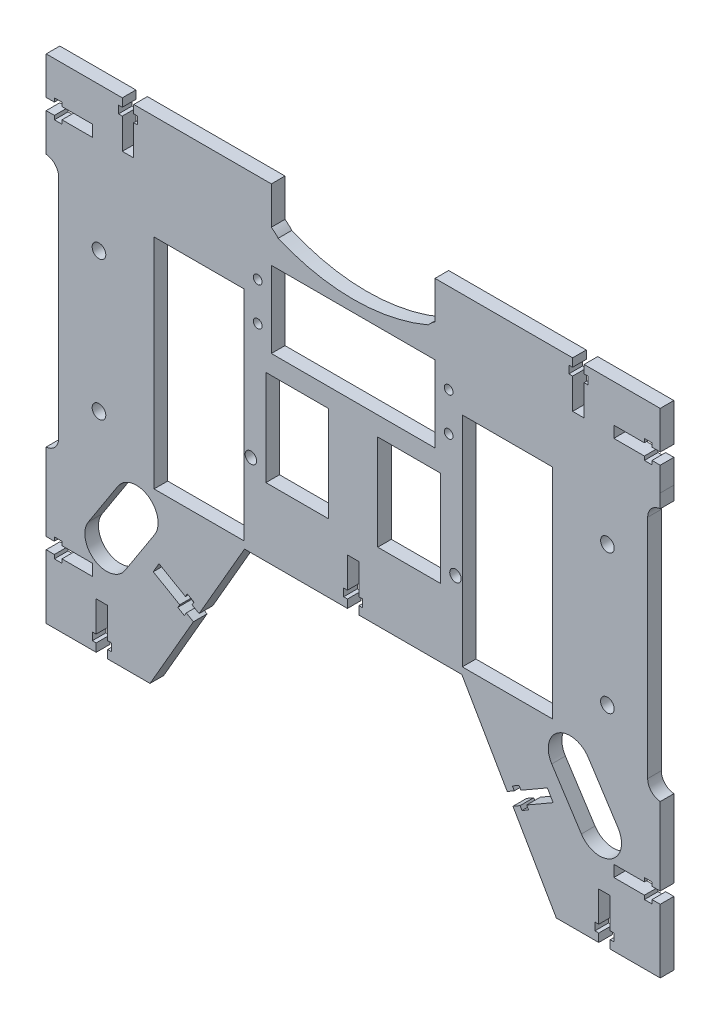
from build123d import *

# Parameters (mm, degrees)
SKETCH1_R           = 2.5
SKETCH1_W           = 33
SKETCH1_H           = 80
SKETCH1_W_2         = 31
SKETCH1_H_2         = 35
BOSS_EXTRUDE1_DEPTH = 5
CUT_EXTRUDE1_DEPTH  = 10
SKETCH3_R           = 1.6
CUT_EXTRUDE2_DEPTH  = 10
CUT_EXTRUDE3_DEPTH  = 5
CUT_EXTRUDE4_DEPTH  = 5
SKETCH6_W           = 3.16837468
SKETCH6_H           = 2.878316338
SKETCH6_W_2         = 2.517728351
SKETCH6_H_2         = 2.409312127
BOSS_EXTRUDE3_DEPTH = 5
CUT_EXTRUDE5_DEPTH  = 5
SKETCH8_W           = 4.185513975
SKETCH8_H           = 1.327509763
CUT_EXTRUDE6_DEPTH  = 5
CUT_EXTRUDE7_DEPTH  = 10
BOSS_EXTRUDE4_DEPTH = 5
SKETCH13_W          = 4.000000001
SKETCH13_H          = 35
SKETCH13_W_2        = 3.999999999
SKETCH13_W_3        = 4
BOSS_EXTRUDE5_DEPTH = 5
SKETCH15_R          = 2.1
CUT_EXTRUDE8_DEPTH  = 5
BOSS_EXTRUDE6_DEPTH = 5
CUT_EXTRUDE9_DEPTH  = 5
CUT_EXTRUDE11_DEPTH = 5


with BuildPart() as part:
    # Sketch1 → Boss-Extrude1 (new body)
    with BuildSketch(Plane.XY):
        with BuildLine():
            Line((71.862411876, -120.884610434), (117.840978496, -120.884610434))
            Line((117.840978496, -120.884610434), (117.840978496, -59.877430624))
            Line((117.840978496, -59.877430624), (113.240978496, -59.877430624))
            ThreePointArc((113.240978496, -59.877430624), (109.705444591, -58.41296453), (108.240978496, -54.877430624))
            Line((108.240978496, -54.877430624), (108.240978496, 28.108209756))
            ThreePointArc((108.240978496, 28.108209756), (109.705444591, 31.643743662), (113.240978496, 33.108209756))
            Line((113.240978496, 33.108209756), (117.839638844, 33.108209756))
            Line((117.839638844, 33.108209756), (117.839282858, 49.903611938))
            Line((117.839282858, 49.903611938), (117.822271173, 69.968834053))
            Line((117.822271173, 69.968834053), (36.921897219, 69.968834053))
            ThreePointArc((36.921897219, 69.968834053), (0.270978496, 60.403611938), (-36.379940226, 69.968834053))
            Line((-36.379940226, 69.968834053), (-117.28031418, 69.968834053))
            Line((-117.28031418, 69.968834053), (-117.297325865, 49.903611938))
            Line((-117.297325865, 49.903611938), (-117.297681851, 33.108209756))
            Line((-117.297681851, 33.108209756), (-112.699021504, 33.108209756))
            ThreePointArc((-112.699021504, 33.108209756), (-109.163487598, 31.643743662), (-107.699021504, 28.108209756))
            Line((-107.699021504, 28.108209756), (-107.699021504, -54.877430624))
            ThreePointArc((-107.699021504, -54.877430624), (-109.163487598, -58.41296453), (-112.699021504, -59.877430624))
            Line((-112.699021504, -59.877430624), (-117.299021504, -59.877430624))
            Line((-117.299021504, -59.877430624), (-117.299021504, -120.884610434))
            Line((-117.299021504, -120.884610434), (-71.320454883, -120.884610434))
            Line((-71.320454883, -120.884610434), (-36.679438732, -60.884610434))
            Line((-36.679438732, -60.884610434), (37.221395725, -60.884610434))
            Line((37.221395725, -60.884610434), (71.862411876, -120.884610434))
        make_face()
        with Locations((-92.929021504, 12.115389566)):
            Circle(SKETCH1_R, mode=Mode.SUBTRACT)
        with Locations((-92.929021504, -38.884610434)):
            Circle(SKETCH1_R, mode=Mode.SUBTRACT)
        with Locations((93.470978496, 12.115389566)):
            Circle(SKETCH1_R, mode=Mode.SUBTRACT)
        with Locations((93.470978496, -38.884610434)):
            Circle(SKETCH1_R, mode=Mode.SUBTRACT)
        with Locations((-56.229021504, -13.384610434)):
            Rectangle(SKETCH1_W, SKETCH1_H, mode=Mode.SUBTRACT)
        with Locations((-20.229021504, -13.384610434)):
            Rectangle(SKETCH1_W_2, SKETCH1_H_2, mode=Mode.SUBTRACT)
        with Locations((20.770978496, -13.384610434)):
            Rectangle(SKETCH1_W_2, SKETCH1_H_2, mode=Mode.SUBTRACT)
        with Locations((56.770978496, -13.384610434)):
            Rectangle(SKETCH1_W, SKETCH1_H, mode=Mode.SUBTRACT)
    extrude(amount=BOSS_EXTRUDE1_DEPTH)

    # Sketch2 → Cut-Extrude1 (cut)
    with BuildSketch(Plane.XY.offset(5)):
        with BuildLine():
            Line((-29.729021504, 60.403611938), (-29.729021504, 66.664976514))
            ThreePointArc((-29.729021504, 66.664976514), (0.270978496, 60.403611938), (30.270978496, 66.664976514))
            Line((30.270978496, 66.664976514), (30.270978496, 60.403611938))
            Line((30.270978496, 60.403611938), (30.270978496, 32.403611938))
            Line((30.270978496, 32.403611938), (-29.729021504, 32.403611938))
            Line((-29.729021504, 32.403611938), (-29.729021504, 60.403611938))
        make_face()
    extrude(amount=-CUT_EXTRUDE1_DEPTH, mode=Mode.SUBTRACT)

    # Sketch3 → Cut-Extrude2 (cut)
    with BuildSketch(Plane.XY.offset(5)):
        with Locations((35.270978497, 32.115389566)):
            Circle(SKETCH3_R)
        with Locations((35.270978497, 18.115389566)):
            Circle(SKETCH3_R)
        with Locations((-34.729021503, 32.115389566)):
            Circle(SKETCH3_R)
        with Locations((-34.729021503, 18.115389566)):
            Circle(SKETCH3_R)
    extrude(amount=-CUT_EXTRUDE2_DEPTH, mode=Mode.SUBTRACT)

    # Sketch4 → Cut-Extrude3 (cut)
    with BuildSketch(Plane.XY.offset(5)):
        with BuildLine():
            ThreePointArc((112.840978496, -59.861404942), (113.040818047, -59.873422597), (113.240978496, -59.877430624))
            Line((113.240978496, -59.877430624), (117.840978496, -59.877430624))
            Line((117.840978496, -59.877430624), (117.840978496, -120.884610434))
            Line((117.840978496, -120.884610434), (71.862411876, -120.884610434))
            Line((71.862411876, -120.884610434), (37.221395725, -60.884610434))
            Line((37.221395725, -60.884610434), (-36.679438732, -60.884610434))
            Line((-36.679438732, -60.884610434), (-71.320454883, -120.884610434))
            Line((-71.320454883, -120.884610434), (-117.299021504, -120.884610434))
            Line((-117.299021504, -120.884610434), (-117.299021504, -59.877430624))
            Line((-117.299021504, -59.877430624), (-112.699021504, -59.877430624))
            ThreePointArc((-112.699021504, -59.877430624), (-112.498861054, -59.873422597), (-112.299021504, -59.861404942))
            Line((-112.299021504, -59.861404942), (-112.299021504, -64.869427421))
            Line((-112.299021504, -64.869427421), (-112.299021504, -115.884610434))
            Line((-112.299021504, -115.884610434), (-74.207206229, -115.884610434))
            Line((-74.207206229, -115.884610434), (-39.566190078, -55.884610434))
            Line((-39.566190078, -55.884610434), (40.108147071, -55.884610434))
            Line((40.108147071, -55.884610434), (74.749163222, -115.884610434))
            Line((74.749163222, -115.884610434), (112.840978496, -115.884610434))
            Line((112.840978496, -115.884610434), (112.840978496, -64.869427421))
            Line((112.840978496, -64.869427421), (112.840978496, -59.861404942))
        make_face()
        with BuildLine():
            ThreePointArc((-112.297576044, 33.092067854), (-112.498136575, 33.104172651), (-112.699021504, 33.108209756))
            Line((-112.699021504, 33.108209756), (-117.297681851, 33.108209756))
            Line((-117.297681851, 33.108209756), (-117.297325865, 49.903611938))
            Line((-117.297325865, 49.903611938), (-117.28031418, 69.968834053))
            Line((-117.28031418, 69.968834053), (-36.379940226, 69.968834053))
            Line((-36.379940226, 69.968834053), (-36.379940226, 64.293063095))
            ThreePointArc((-36.379940226, 64.293063095), (-37.022706456, 64.628043677), (-37.662411338, 64.968834053))
            Line((-37.662411338, 64.968834053), (-112.28455148, 64.968834053))
            Line((-112.28455148, 64.968834053), (-112.29732591, 49.901439401))
            Line((-112.29732591, 49.901439401), (-112.297576044, 38.100148584))
            Line((-112.297576044, 38.100148584), (-112.297576044, 33.092067854))
        make_face()
        with BuildLine():
            ThreePointArc((113.240978496, 33.108209756), (113.040093568, 33.104172651), (112.839533037, 33.092067854))
            Line((112.839533037, 33.092067854), (112.839533037, 38.100148584))
            Line((112.839533037, 38.100148584), (112.839282903, 49.901439402))
            Line((112.839282903, 49.901439402), (112.826508473, 64.968834053))
            Line((112.826508473, 64.968834053), (38.204368331, 64.968834053))
            ThreePointArc((38.204368331, 64.968834053), (37.564663449, 64.628043677), (36.921897219, 64.293063095))
            Line((36.921897219, 64.293063095), (36.921897219, 69.968834053))
            Line((36.921897219, 69.968834053), (117.822271173, 69.968834053))
            Line((117.822271173, 69.968834053), (117.839282858, 49.903611938))
            Line((117.839282858, 49.903611938), (117.839638844, 33.108209756))
            Line((117.839638844, 33.108209756), (113.240978496, 33.108209756))
        make_face()
    extrude(amount=-CUT_EXTRUDE3_DEPTH, mode=Mode.SUBTRACT)

    # Sketch5 → Cut-Extrude4 (cut)
    with BuildSketch(Plane.XY.offset(5)):
        with BuildLine():
            Line((-36.379940226, 64.968834053), (-29.729021504, 64.968834053))
            Line((-29.729021504, 64.968834053), (-29.729021504, 66.664976514))
            ThreePointArc((-29.729021504, 66.664976514), (-33.095398446, 68.234535052), (-36.379940226, 69.968834053))
            Line((-36.379940226, 69.968834053), (-36.379940226, 64.968834053))
        make_face()
        with BuildLine():
            Line((36.921897219, 69.968834053), (36.921897219, 64.968834053))
            Line((36.921897219, 64.968834053), (30.270978497, 64.968834053))
            Line((30.270978497, 64.968834053), (30.270978497, 66.664976514))
            ThreePointArc((30.270978497, 66.664976514), (33.637355439, 68.234535052), (36.921897219, 69.968834053))
        make_face()
    extrude(amount=-CUT_EXTRUDE4_DEPTH, mode=Mode.SUBTRACT)

    # Sketch6 → Boss-Extrude3 (add)
    with BuildSketch(Plane.XY.offset(5)):
        with Locations((-36.078223998, 63.529675884)):
            Rectangle(SKETCH6_W, SKETCH6_H)
        with Locations((36.945504156, 63.76417799)):
            Rectangle(SKETCH6_W_2, SKETCH6_H_2)
    extrude(amount=-BOSS_EXTRUDE3_DEPTH)

    # Sketch7 → Cut-Extrude5 (cut)
    with BuildSketch(Plane.XY.offset(5)):
        Polygon((-1.828604275, -52.884610434), (-1.828604275, -55.884610434), (2.371395725, -55.884610434), (2.371395725, -52.884610434), (3.771395725, -52.884610434), (3.771395725, -50.084610434), (2.371395725, -50.084610434), (2.371395725, -38.884610434), (-1.828604275, -38.884610434), (-1.828604275, -50.084610434), (-3.228604275, -50.084610434), (-3.228604275, -52.884610434), align=None)
        Polygon((-58.308565752, -88.347357356), (-56.208565752, -84.71005066), (-58.806641963, -83.21005066), (-58.106641963, -81.997615095), (-60.531513094, -80.597615095), (-61.231513094, -81.81005066), (-70.930997615, -76.210050661), (-73.030997615, -79.847357357), (-63.331513094, -85.447357356), (-64.031513094, -86.659792921), (-61.606641963, -88.059792921), (-60.906641963, -86.847357356), align=None)
        Polygon((-93.954021504, -115.884610434), (-89.754021504, -115.884610434), (-89.754021504, -112.884610437), (-88.354021504, -112.884610437), (-88.354021504, -110.084610437), (-89.754021504, -110.084610437), (-89.754021504, -98.884610434), (-93.954021504, -98.884610434), (-93.954021504, -110.084610437), (-95.354021504, -110.084610437), (-95.354021504, -112.884610437), (-93.954021504, -112.884610437), align=None)
        Polygon((90.296812953, -112.884610437), (90.296812953, -115.884610434), (94.496812953, -115.884610434), (94.496812953, -112.884610437), (95.896812953, -112.884610437), (95.896812953, -110.084610437), (94.496812953, -110.084610437), (94.496812953, -98.884610434), (90.296812953, -98.884610434), (90.296812953, -110.084610437), (88.896812953, -110.084610437), (88.896812953, -112.884610437), align=None)
        Polygon((-112.299021504, -88.279610434), (-112.299021504, -92.479610434), (-109.299021504, -92.479610434), (-109.299021504, -93.879610434), (-106.499021504, -93.879610434), (-106.499021504, -92.479610434), (-95.299021504, -92.479610434), (-95.299021504, -88.279610434), (-106.499021504, -88.279610434), (-106.499021504, -86.879610434), (-109.299021504, -86.879610434), (-109.299021504, -88.279610434), align=None)
        Polygon((109.841812953, -92.479610434), (112.840978496, -92.479610434), (112.840978496, -88.279610434), (109.841812953, -88.279610434), (109.841812953, -86.879610434), (107.041812953, -86.879610434), (107.041812953, -88.279610434), (95.841812953, -88.279610434), (95.841812953, -92.479610434), (107.041812953, -92.479610434), (107.041812953, -93.879610434), (109.841812953, -93.879610434), align=None)
        Polygon((109.822731675, 46.938834051), (112.839345697, 46.938834051), (112.839301186, 49.038834051), (112.839282903, 49.901439402), (112.838281724, 51.082326308), (112.821897219, 51.138834051), (109.822731675, 51.138834051), (109.822731675, 52.538834051), (107.022731675, 52.538834051), (107.022731675, 51.138834051), (95.822731675, 51.138834051), (95.822731675, 46.938834051), (107.022731675, 46.938834051), (107.022731675, 45.538834051), (109.822731675, 45.538834051), align=None)
        Polygon((-112.297388704, 46.938834051), (-109.279940226, 46.938834051), (-109.279940226, 45.538834051), (-106.479940226, 45.538834051), (-106.479940226, 46.938834051), (-95.279940226, 46.938834051), (-95.279940226, 51.138834051), (-106.479940226, 51.138834051), (-106.479940226, 52.538834051), (-109.279940226, 52.538834051), (-109.279940226, 51.138834051), (-112.279940226, 51.138834051), (-112.296869511, 50.439759816), (-112.29732591, 49.901439401), (-112.297344193, 49.038834051), align=None)
        Polygon((79.472731675, 61.968834051), (79.472731675, 64.968834053), (75.272731675, 64.968834053), (75.272731675, 61.968834051), (73.872731675, 61.968834051), (73.872731675, 59.168834051), (75.272731675, 59.168834051), (75.272731675, 47.968834053), (79.472731675, 47.968834053), (79.472731675, 59.168834051), (80.872731675, 59.168834051), (80.872731675, 61.968834051), align=None)
        Polygon((-74.729940226, 64.968834053), (-78.929940226, 64.968834053), (-78.929940226, 61.968834051), (-80.329940226, 61.968834051), (-80.329940226, 59.168834051), (-78.929940226, 59.168834051), (-78.929940226, 47.968834053), (-74.729940226, 47.968834053), (-74.729940226, 59.168834051), (-73.329940226, 59.168834051), (-73.329940226, 61.968834051), (-74.729940226, 61.968834051), align=None)
        Polygon((64.574304543, -86.659792921), (63.874304543, -85.447357356), (73.573789064, -79.847357357), (71.473789064, -76.210050661), (61.774304543, -81.81005066), (61.074304543, -80.597615095), (58.649433412, -81.997615095), (59.349433412, -83.21005066), (56.751357201, -84.71005066), (58.851357201, -88.347357356), (61.449433412, -86.847357356), (62.149433412, -88.059792921), align=None)
    extrude(amount=-CUT_EXTRUDE5_DEPTH, mode=Mode.SUBTRACT)

    # Sketch8 → Cut-Extrude6 (cut)
    with BuildSketch(Plane.XY.offset(5)):
        Polygon((59.349433412, -83.21005066), (55.722136922, -85.304271265), (57.822136543, -88.941577306), (61.449433412, -86.847357356), align=None)
        with Locations((-111.372697214, 50.47507917)):
            Rectangle(SKETCH8_W, SKETCH8_H)
    extrude(amount=-CUT_EXTRUDE6_DEPTH, mode=Mode.SUBTRACT)

    # Sketch9 → Cut-Extrude7 (cut)
    with BuildSketch(Plane.XY.offset(5)):
        Polygon((-29.729021504, 32.403611938), (-29.729021503, 11.115389566), (30.270978497, 11.115389566), (30.270978496, 32.403611938), align=None)
    extrude(amount=-CUT_EXTRUDE7_DEPTH, mode=Mode.SUBTRACT)

    # Sketch10 → Boss-Extrude4 (add)
    with BuildSketch(Plane(origin=(0, 0, 0), x_dir=(-1, 0, 0), z_dir=(0, 0, -1))):
        with BuildLine():
            Line((-30.270978497, 39.115389566), (29.729021504, 39.115389566))
            Line((29.729021504, 39.115389566), (29.729021504, 51.203031109))
            ThreePointArc((29.729021504, 51.203031109), (28.415678695, 50.147376411), (27.229021504, 48.951081763))
            ThreePointArc((27.229021504, 48.951081763), (-0.270978497, 43.323047711), (-27.770978497, 48.951081763))
            ThreePointArc((-27.770978497, 48.951081763), (-28.957635688, 50.147376411), (-30.270978497, 51.203031109))
            Line((-30.270978497, 51.203031109), (-30.270978497, 39.115389566))
        make_face()
    extrude(amount=-BOSS_EXTRUDE4_DEPTH)

    # Sketch13 → Boss-Extrude5 (add)
    with BuildSketch(Plane.XY.offset(5)):
        with Locations((-33.729021504, -13.384610434)):
            Rectangle(SKETCH13_W, SKETCH13_H)
        with Locations((-6.729021504, -13.384610434)):
            Rectangle(SKETCH13_W_2, SKETCH13_H)
        with Locations((7.270978496, -13.384610434)):
            Rectangle(SKETCH13_W_3, SKETCH13_H)
        with Locations((34.270978496, -13.384610434)):
            Rectangle(SKETCH13_W_3, SKETCH13_H)
    extrude(amount=-BOSS_EXTRUDE5_DEPTH)

    # Sketch15 → Cut-Extrude8 (cut)
    with BuildSketch(Plane.XY.offset(5)):
        with Locations((37.770978496, -25.668665947)):
            Circle(SKETCH15_R)
        with Locations(Location((-37.229021503, -25.668665947, 0), (0, 0, 180))):
            Circle(SKETCH15_R)
    extrude(amount=-CUT_EXTRUDE8_DEPTH, mode=Mode.SUBTRACT)

    # Sketch16 → Boss-Extrude6 (add)
    with BuildSketch(Plane.XY.offset(5)):
        Polygon((-78.929940226, 64.968834053), (-78.929940226, 61.968834051), (-80.329940226, 61.968834051), (-80.329940226, 59.168834051), (-78.929940226, 59.168834051), (-78.929940226, 47.968834053), (-74.729940226, 47.968834053), (-74.729940226, 59.168834051), (-73.329940226, 59.168834051), (-73.329940226, 61.968834051), (-74.729940226, 61.968834051), (-74.729940226, 64.968834053), align=None)
        Polygon((80.872731675, 59.168834051), (79.472731675, 59.168834051), (79.472731675, 47.968834053), (75.272731675, 47.968834053), (75.272731675, 59.168834051), (73.872731675, 59.168834051), (73.872731675, 61.968834051), (75.272731675, 61.968834051), (75.272731675, 64.968834053), (79.472731675, 64.968834053), (79.472731675, 61.968834051), (80.872731675, 61.968834051), align=None)
    extrude(amount=-BOSS_EXTRUDE6_DEPTH)

    # Sketch17 → Cut-Extrude9 (cut)
    with BuildSketch(Plane.XY.offset(5)):
        Polygon((84.922271173, 64.968834053), (80.722271173, 64.968834053), (80.722271173, 61.968834053), (79.322271173, 61.968834053), (79.322271173, 59.168834053), (80.722271173, 59.168834053), (80.722271173, 47.968834053), (84.922271173, 47.968834053), (84.922271173, 59.168834053), (86.322271173, 59.168834053), (86.322271173, 61.968834053), (84.922271173, 61.968834053), align=None)
        Polygon((-80.179479724, 64.968834053), (-80.179479724, 61.968834053), (-78.779479724, 61.968834053), (-78.779479724, 59.168834053), (-80.179479724, 59.168834053), (-80.179479724, 47.968834053), (-84.379479724, 47.968834053), (-84.379479724, 59.168834053), (-85.779479724, 59.168834053), (-85.779479724, 61.968834053), (-84.379479724, 61.968834053), (-84.379479724, 64.968834053), align=None)
    extrude(amount=-CUT_EXTRUDE9_DEPTH, mode=Mode.SUBTRACT)

    # Sketch18 → Cut-Extrude11 (cut)
    with BuildSketch(Plane.XY.offset(5)):
        with BuildLine():
            Line((-96.825475067, -75.909284142), (-85.963542634, -59.115879966))
            ThreePointArc((-85.963542634, -59.115879966), (-74.90140799, -56.743291269), (-72.528819293, -67.805425913))
            Line((-72.528819293, -67.805425913), (-83.390751726, -84.598830089))
            ThreePointArc((-83.390751726, -84.598830089), (-94.45288637, -86.971418786), (-96.825475067, -75.909284142))
        make_face()
        with BuildLine():
            Line((97.368266516, -75.909284142), (86.506334083, -59.115879966))
            ThreePointArc((86.506334083, -59.115879966), (75.444199439, -56.743291269), (73.071610742, -67.805425913))
            Line((73.071610742, -67.805425913), (83.933543175, -84.598830089))
            ThreePointArc((83.933543175, -84.598830089), (94.995677819, -86.971418786), (97.368266516, -75.909284142))
        make_face()
    extrude(amount=-CUT_EXTRUDE11_DEPTH, mode=Mode.SUBTRACT)


solid = part.part
